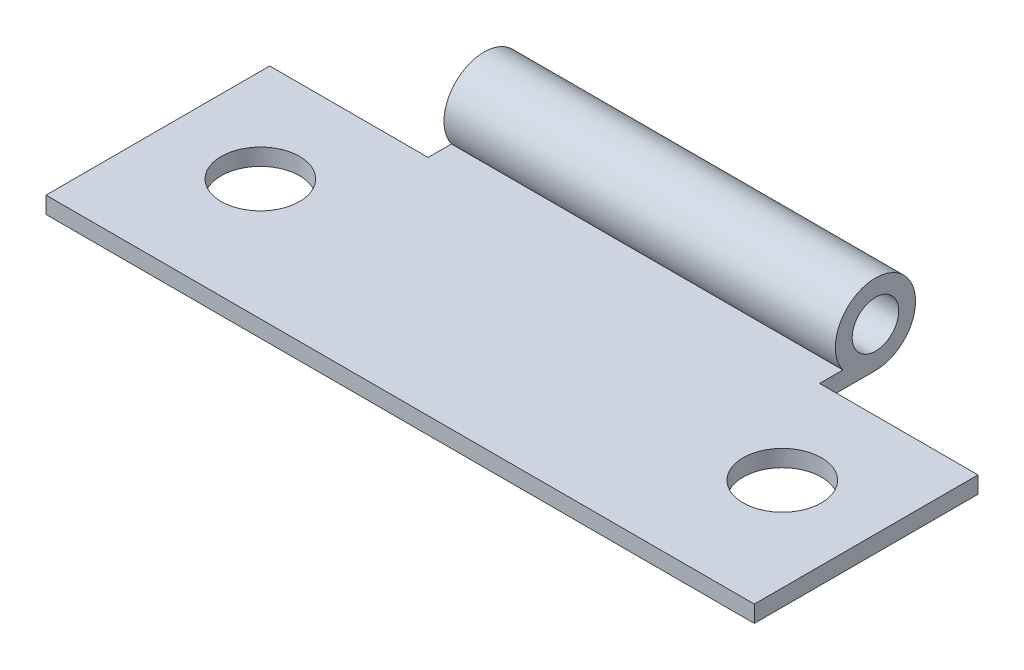
from build123d import *

# Parameters (mm, degrees)
SKETCH_1_R          = 1.25
EXTRUDE_1_DEPTH     = 38
SKETCH_2_R          = 2.1
SKETCH_2_W          = 8.5
SKETCH_2_H          = 8.890130192
CUT_EXTRUDE_1_DEPTH = 19


with BuildPart() as part:
    # 草图1 → 凸台-拉伸1 (new body)
    with BuildSketch(Plane(origin=(0, 0, 0), x_dir=(0, 0, -1), z_dir=(1, 0, 0))):
        with BuildLine():
            Line((0, -2.15), (-15, -2.15))
            Line((-15, -2.15), (-15, -1.25))
            Line((-15, -1.25), (-1.749285568, -1.25))
            ThreePointArc((-1.749285568, -1.25), (0.983615779, 1.911805429), (0, -2.15))
        make_face()
        Circle(SKETCH_1_R, mode=Mode.SUBTRACT)
    extrude(amount=EXTRUDE_1_DEPTH)

    # 草图2 → 切除-拉伸1 (cut, symmetric)
    with BuildSketch(Plane(origin=(0, 0, 0), x_dir=(1, 0, 0), z_dir=(0, 1, 0))):
        with Locations((33, -8.5)):
            Circle(SKETCH_2_R)
        with Locations((5, -8.5)):
            Circle(SKETCH_2_R)
        with Locations((33.75, 1.445065096)):
            Rectangle(SKETCH_2_W, SKETCH_2_H)
        with Locations((4.25, 1.445065096)):
            Rectangle(SKETCH_2_W, SKETCH_2_H)
    extrude(amount=CUT_EXTRUDE_1_DEPTH, both=True, mode=Mode.SUBTRACT)


solid = part.part
